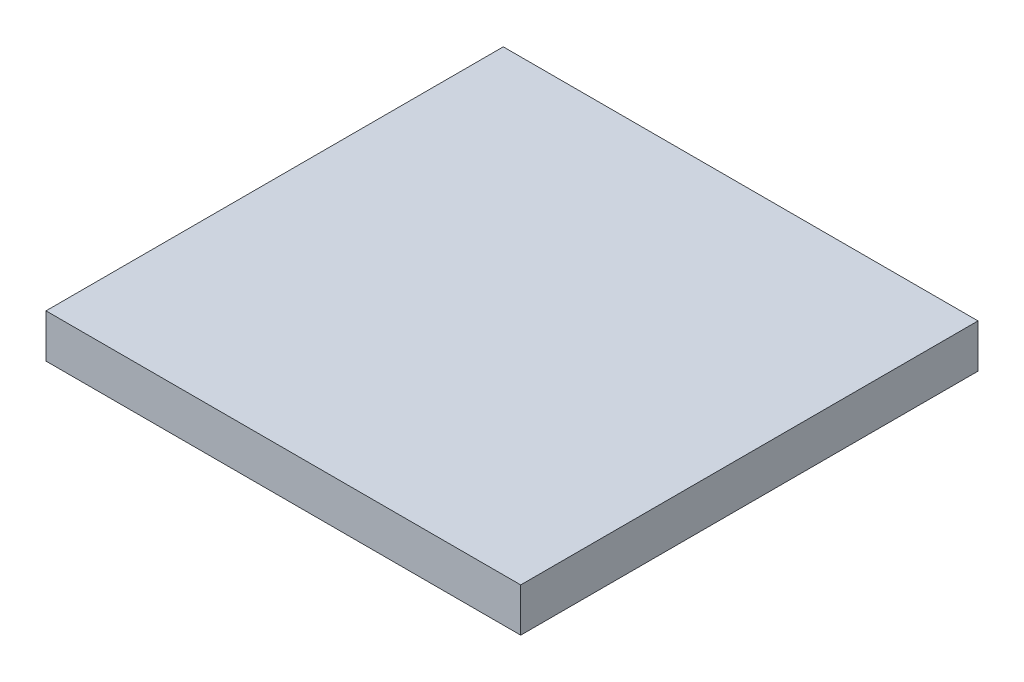
from build123d import *

# Parameters (mm, degrees)
SKETCH1_W           = 27.686
SKETCH1_H           = 26.67
BOSS_EXTRUDE1_DEPTH = 2.54


with BuildPart() as part:
    # Sketch1 → Boss-Extrude1 (new body)
    with BuildSketch(Plane(origin=(0, 0, 0), x_dir=(1, 0, 0), z_dir=(0, 1, 0))):
        Rectangle(SKETCH1_W, SKETCH1_H)
    extrude(amount=BOSS_EXTRUDE1_DEPTH)


solid = part.part
